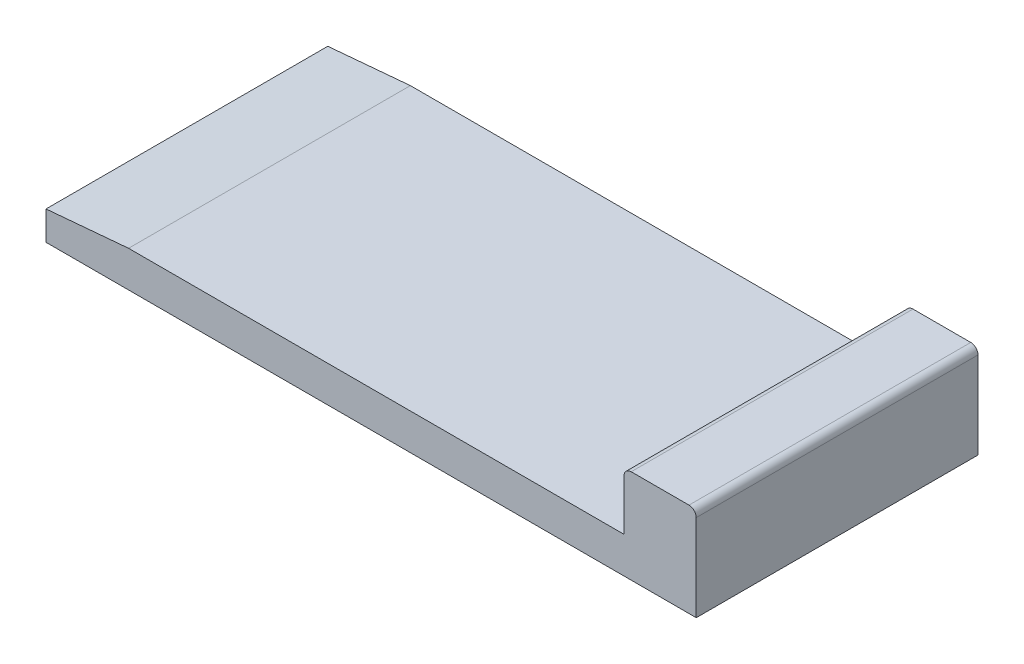
from build123d import *

# Parameters (mm, degrees)
SKETCH1_W           = 45
SKETCH1_H           = 19.5
BOSS_EXTRUDE1_DEPTH = 2.5
SKETCH2_W           = 5
SKETCH2_H           = 19.5
BOSS_EXTRUDE2_DEPTH = 4
FILLET1_R           = 0.5
CHAMFER1_SIZE       = 0.5
CHAMFER1_SIZE2      = 5.715026151


with BuildPart() as part:
    # Sketch1 → Boss-Extrude1 (new body)
    with BuildSketch(Plane(origin=(0, 0, 0), x_dir=(1, 0, 0), z_dir=(0, 1, 0))):
        with Locations((1.28516624, -1.137468031)):
            Rectangle(SKETCH1_W, SKETCH1_H)
    extrude(amount=BOSS_EXTRUDE1_DEPTH)

    # Sketch2 → Boss-Extrude2 (add)
    with BuildSketch(Plane(origin=(0, 2.5, 0), x_dir=(1, 0, 0), z_dir=(0, 1, 0))):
        with Locations((21.28516624, -1.137468031)):
            Rectangle(SKETCH2_W, SKETCH2_H)
    extrude(amount=BOSS_EXTRUDE2_DEPTH)

    # Fillet1
    fillet1_edges = [part.edges().sort_by_distance(p)[0] for p in [
        (23.78516624, 6.5, 1.137468031),
        (18.78516624, 6.5, 1.137468031),
    ]]
    fillet(fillet1_edges, radius=FILLET1_R)

    # Chamfer1
    chamfer1_edges = [part.edges().sort_by_distance(p)[0] for p in [
        (-21.21483376, 2.5, 1.137468031),
    ]]
    chamfer1_side = [part.faces().sort_by_distance(p)[0] for p in [
        (-21.21483376, 1.25, 1.137468031),
    ]]
    chamfer(chamfer1_edges, length=CHAMFER1_SIZE, length2=CHAMFER1_SIZE2, reference=chamfer1_side[0])


solid = part.part
